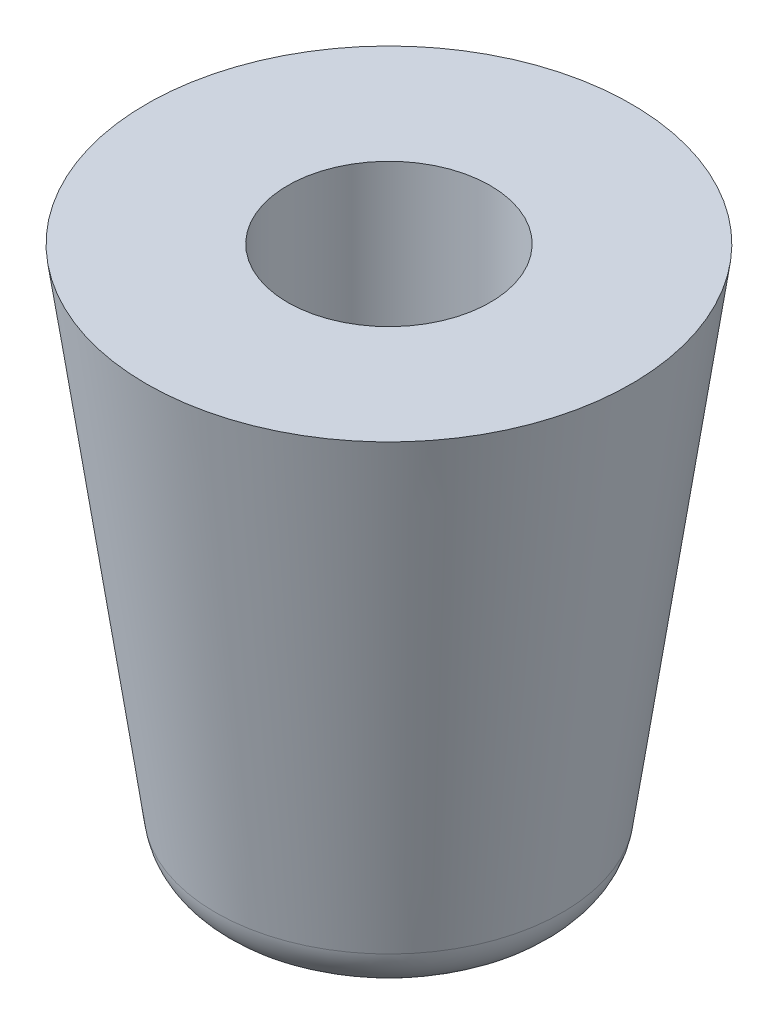
from build123d import *

# Parameters (mm, degrees)
SKETCH1_R           = 5.715
BOSS_EXTRUDE1_DEPTH = 12.7
BOSS_EXTRUDE1_TAPER = 8
SKETCH2_R           = 2.3876
CUT_EXTRUDE1_DEPTH  = 10
FILLET1_R           = 1.27


with BuildPart() as part:
    # Sketch1 → Boss-Extrude1 (new body)
    with BuildSketch(Plane(origin=(0, 0, 0), x_dir=(1, 0, 0), z_dir=(0, 1, 0))):
        Circle(SKETCH1_R)
    extrude(amount=-BOSS_EXTRUDE1_DEPTH, taper=BOSS_EXTRUDE1_TAPER)

    # Sketch2 → Cut-Extrude1 (cut)
    with BuildSketch(Plane(origin=(0, 0, 0), x_dir=(1, 0, 0), z_dir=(0, 1, 0))):
        Circle(SKETCH2_R)
    extrude(amount=-CUT_EXTRUDE1_DEPTH, mode=Mode.SUBTRACT)

    # Fillet1
    fillet1_edges = [part.edges().sort_by_distance(p)[0] for p in [
        (-3.930131399, -12.7, 0),
    ]]
    fillet(fillet1_edges, radius=FILLET1_R)


solid = part.part
